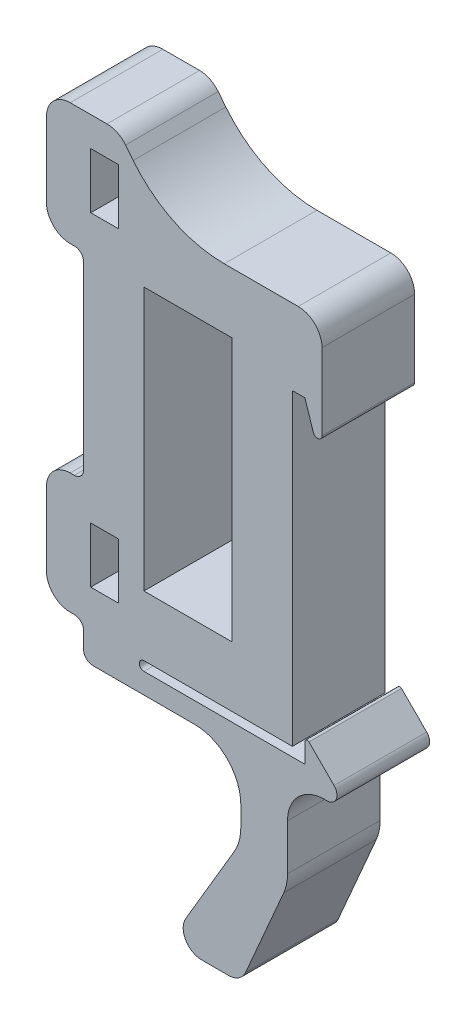
from build123d import *

# Parameters (mm, degrees)
SKETCH2_W           = 9.52
SKETCH2_H           = 28.42
SKETCH2_W_2         = 3.01
SKETCH2_H_2         = 6
BOSS_EXTRUDE1_DEPTH = 10
SKETCH4_R           = 1.852493383
SKETCH4_R_2         = 1.85249338
CUT_EXTRUDE1_DEPTH  = 9.5


with BuildPart() as part:
    # Sketch2 → Boss-Extrude1 (new body)
    with BuildSketch(Plane.XY):
        with BuildLine():
            Line((0, 66.651771766), (0, 33.391771766))
            Line((0, 33.391771766), (-16.03, 33.391771766))
            ThreePointArc((-16.03, 33.391771766), (-16.53, 32.891771766), (-16.03, 32.391771766))
            Line((-16.03, 32.391771766), (1.352234191, 32.391771766))
            Line((1.352234191, 32.391771766), (1.352234191, 34.518218659))
            ThreePointArc((1.352234191, 34.518218659), (1.506462672, 34.749146821), (1.77885672, 34.695149386))
            Line((1.77885672, 34.695149386), (4.496782459, 31.98195805))
            ThreePointArc((4.496782459, 31.98195805), (4.727391952, 30.826554208), (3.747902937, 30.171771766))
            Line((3.747902937, 30.171771766), (3.470297616, 30.171771766))
            ThreePointArc((3.470297616, 30.171771766), (0.641870491, 29.00019889), (-0.529702384, 26.171771766))
            Line((-0.529702384, 26.171771766), (-0.529702384, 21.208235908))
            ThreePointArc((-0.529702384, 21.208235908), (-0.633785571, 20.193347464), (-0.941701806, 19.220712149))
            Line((-0.941701806, 19.220712149), (-5.050790824, 9.735289546))
            ThreePointArc((-5.050790824, 9.735289546), (-5.788270464, 8.858470858), (-6.885991056, 8.53029905))
            Line((-6.885991056, 8.53029905), (-9.79055056, 8.53029905))
            ThreePointArc((-9.79055056, 8.53029905), (-11.527191752, 9.538292312), (-11.513310325, 11.546221681))
            Line((-11.513310325, 11.546221681), (-6.265893795, 20.444574564))
            ThreePointArc((-6.265893795, 20.444574564), (-5.74917957, 21.668040962), (-5.572793209, 22.984381141))
            Line((-5.572793209, 22.984381141), (-5.572793209, 25.171771766))
            ThreePointArc((-5.572793209, 25.171771766), (-7.037259303, 28.707305672), (-10.572793209, 30.171771766))
            Line((-10.572793209, 30.171771766), (-21.54, 30.171771766))
            ThreePointArc((-21.54, 30.171771766), (-22.247106781, 30.464664985), (-22.54, 31.171771766))
            Line((-22.54, 31.171771766), (-22.54, 32.942649485))
            ThreePointArc((-22.54, 32.942649485), (-22.832893219, 33.649756266), (-23.54, 33.942649485))
            Line((-23.54, 33.942649485), (-23.98462025, 33.942649485))
            ThreePointArc((-23.98462025, 33.942649485), (-25.801884678, 34.695385057), (-26.55462025, 36.512649485))
            Line((-26.55462025, 36.512649485), (-26.55462025, 44.391771766))
            ThreePointArc((-26.55462025, 44.391771766), (-25.801884678, 46.209036193), (-23.98462025, 46.961771766))
            Line((-23.98462025, 46.961771766), (-23.54, 46.961771766))
            ThreePointArc((-23.54, 46.961771766), (-22.832893219, 47.254664985), (-22.54, 47.961771766))
            Line((-22.54, 47.961771766), (-22.54, 67.401771766))
            ThreePointArc((-22.54, 67.401771766), (-22.832893219, 68.108878547), (-23.54, 68.401771766))
            Line((-23.54, 68.401771766), (-23.98462025, 68.401771766))
            ThreePointArc((-23.98462025, 68.401771766), (-25.801884678, 69.154507338), (-26.55462025, 70.971771766))
            Line((-26.55462025, 70.971771766), (-26.55462025, 77.401771766))
            Line((-26.55462025, 77.401771766), (-26.55462025, 79.000903717))
            ThreePointArc((-26.55462025, 79.000903717), (-25.801884678, 80.818168145), (-23.98462025, 81.570903717))
            Line((-23.98462025, 81.570903717), (-20.021565093, 81.570903717))
            ThreePointArc((-20.021565093, 81.570903717), (-18.905624991, 81.31597989), (-18.011069886, 80.601781295))
            Line((-18.011069886, 80.601781295), (-17.190935487, 79.571798553))
            ThreePointArc((-17.190935487, 79.571798553), (-12.815621218, 76.078617097), (-7.357501728, 74.831771766))
            Line((-7.357501728, 74.831771766), (0.623852111, 74.831771766))
            ThreePointArc((0.623852111, 74.831771766), (2.441116539, 74.079036193), (3.193852111, 72.261771766))
            Line((3.193852111, 72.261771766), (3.193852111, 64.016682225))
            ThreePointArc((3.193852111, 64.016682225), (2.79053513, 63.543838386), (2.26, 63.867533241))
            Line((2.26, 63.867533241), (1.347357771, 66.651771766))
            Line((1.347357771, 66.651771766), (0, 66.651771766))
        make_face()
        with Locations((-11.27, 54.111771766)):
            Rectangle(SKETCH2_W, SKETCH2_H, mode=Mode.SUBTRACT)
        with Locations((-20.2649024, 75.392647139)):
            Rectangle(SKETCH2_W_2, SKETCH2_H_2, mode=Mode.SUBTRACT)
        with Locations((-20.2649024, 40.392647139)):
            Rectangle(SKETCH2_W_2, SKETCH2_H_2, mode=Mode.SUBTRACT)
    extrude(amount=BOSS_EXTRUDE1_DEPTH)

    # Sketch4 → Cut-Extrude1 (cut)
    with BuildSketch(Plane.ZY.offset(26.55462025)):
        with Locations((5, 75.452210625)):
            Circle(SKETCH4_R)
        with Locations((5, 40.452210625)):
            Circle(SKETCH4_R_2)
    extrude(amount=-CUT_EXTRUDE1_DEPTH, mode=Mode.SUBTRACT)


solid = part.part
